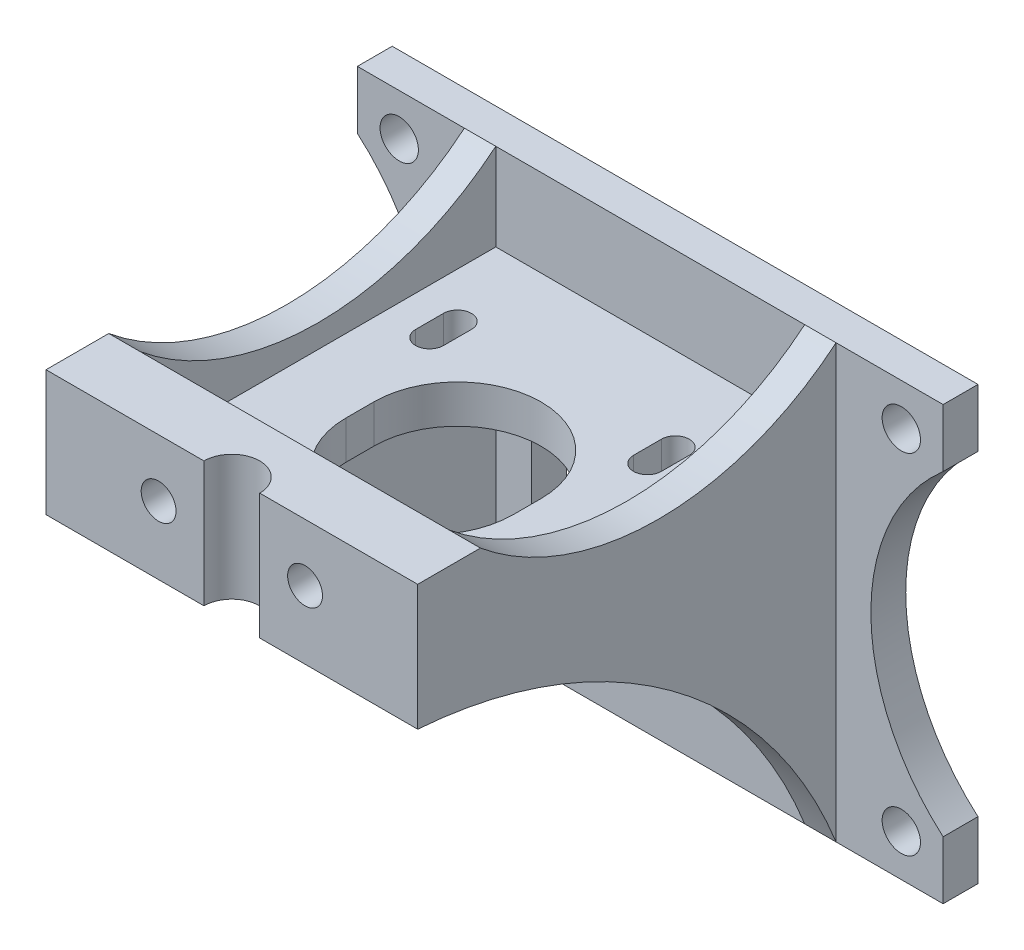
from build123d import *

# Parameters (mm, degrees)
SKETCH2_R                = 2.75
SKETCH2_W                = 34
SKETCH2_H                = 34
BOSS_EXTRUDE1_DEPTH      = 5
SKETCH3_W                = 4.5
SKETCH3_H                = 44
SKETCH3_H_2              = 18
SKETCH3_W_2              = 44.3
BOSS_EXTRUDE2_DEPTH      = 60
CUT_EXTRUDE1_DEPTH       = 16.35
CUT_EXTRUDE1_DEPTH_BACK  = 60
CUT_EXTRUDE3_DEPTH       = 16.35
CUT_EXTRUDE3_DEPTH_BACK  = 60
CUT_EXTRUDE6_REACH       = 25.5
CUT_EXTRUDE6_START       = -5.5
SKETCH9_W                = 44.3
SKETCH9_H                = 51
CUT_EXTRUDE7_DEPTH       = 5.5
LPATTERN1_COUNT          = 2
LPATTERN1_PITCH          = 31.25
LPATTERN2_COUNT          = 2
LPATTERN2_PITCH          = 31
LPATTERN2_COPY_1_DEPTH   = 5.5
CUT_EXTRUDE8_DEPTH       = 10
CUT_EXTRUDE10_DEPTH      = 45
CUT_EXTRUDE10_DEPTH_BACK = 19
SKETCH15_R               = 2.5
CUT_EXTRUDE11_DEPTH      = 4.6
LPATTERN3_COUNT          = 2
LPATTERN3_PITCH          = 21


with BuildPart() as part:
    # Sketch2 → Boss-Extrude1 (new body)
    with BuildSketch(Plane.XY):
        with BuildLine():
            Line((0, -53.68), (0, -62))
            Line((0, -62), (84, -62))
            Line((84, -62), (84, -53.68))
            ThreePointArc((84, -53.68), (73.637148469, -31), (84, -8.32))
            Line((84, -8.32), (84, 0))
            Line((84, 0), (0, 0))
            Line((0, 0), (0, -8.32))
            ThreePointArc((0, -8.32), (10.362851531, -31), (0, -53.68))
        make_face()
        with Locations((6, -6)):
            Circle(SKETCH2_R, mode=Mode.SUBTRACT)
        with Locations((78, -56)):
            Circle(SKETCH2_R, mode=Mode.SUBTRACT)
        with Locations((6, -56)):
            Circle(SKETCH2_R, mode=Mode.SUBTRACT)
        with Locations((78, -6)):
            Circle(SKETCH2_R, mode=Mode.SUBTRACT)
        with Locations((42, -37)):
            Rectangle(SKETCH2_W, SKETCH2_H, mode=Mode.SUBTRACT)
    extrude(amount=BOSS_EXTRUDE1_DEPTH)

    # Sketch3 → Boss-Extrude2 (add)
    with BuildSketch(Plane.XY.offset(5)):
        with Locations((17.6, -40)):
            Rectangle(SKETCH3_W, SKETCH3_H)
        with Locations((66.4, -40)):
            Rectangle(SKETCH3_W, SKETCH3_H)
        with Locations((66.4, -9)):
            Rectangle(SKETCH3_W, SKETCH3_H_2)
        with Locations((17.6, -9)):
            Rectangle(SKETCH3_W, SKETCH3_H_2)
        with Locations((42, -9)):
            Rectangle(SKETCH3_W_2, SKETCH3_H_2)
    extrude(amount=BOSS_EXTRUDE2_DEPTH)

    # Sketch6 → Cut-Extrude1 (cut, two sides)
    with BuildSketch(Plane(origin=(68.65, 0, 0), x_dir=(0, 0, -1), z_dir=(1, 0, 0))) as cut_extrude1_sk:
        with BuildLine():
            Line((62.328372383, -231.688052054), (-5, -62))
            ThreePointArc((-5, -62), (-28.669965475, -31.368134738), (-65, -18))
            Line((-65, -18), (-247.078635565, -4.789579558))
            Line((-247.078635565, -4.789579558), (-462.994068413, -299.219715259))
            Line((-462.994068413, -299.219715259), (-153.587060464, -526.118187755))
            Line((-153.587060464, -526.118187755), (62.328372383, -231.688052054))
        make_face()
    extrude(amount=CUT_EXTRUDE1_DEPTH, mode=Mode.SUBTRACT)
    extrude(cut_extrude1_sk.sketch, amount=-CUT_EXTRUDE1_DEPTH_BACK, mode=Mode.SUBTRACT)

    # Sketch7 → Cut-Extrude3 (cut, two sides)
    with BuildSketch(Plane(origin=(68.65, 0, 0), x_dir=(0, 0, -1), z_dir=(1, 0, 0))) as cut_extrude3_sk:
        with BuildLine():
            ThreePointArc((-56, 0), (-30.5, -9.181985788), (-5, 0))
            Line((-5, 0), (-56, 0))
        make_face()
    extrude(amount=CUT_EXTRUDE3_DEPTH, mode=Mode.SUBTRACT)
    extrude(cut_extrude3_sk.sketch, amount=-CUT_EXTRUDE3_DEPTH_BACK, mode=Mode.SUBTRACT)

    # Sketch9 → Cut-Extrude6 (cut, up to next)
    with BuildSketch(Plane.XZ.offset(18).offset(CUT_EXTRUDE6_START), mode=Mode.PRIVATE) as cut_extrude6_sk1:
        with Locations((42, 30.5)):
            Rectangle(SKETCH9_W, SKETCH9_H)
    cut_extrude6_tool1 = extrude(cut_extrude6_sk1.sketch, amount=-CUT_EXTRUDE6_REACH, mode=Mode.PRIVATE) & part.part
    add(cut_extrude6_tool1.solids().sort_by_distance((42, -12.5, 30.5))[0], mode=Mode.SUBTRACT)

    # Sketch10 → Cut-Extrude7 (cut)
    with BuildSketch(Plane(origin=(0, -12.5, 0), x_dir=(1, 0, 0), z_dir=(0, 1, 0))):
        with BuildLine():
            Line((28.35, -17), (28.35, -21))
            ThreePointArc((28.35, -21), (26.35, -23), (24.35, -21))
            Line((24.35, -21), (24.35, -17))
            ThreePointArc((24.35, -17), (26.35, -15), (28.35, -17))
        make_face()
    cut_extrude7 = extrude(amount=-CUT_EXTRUDE7_DEPTH, mode=Mode.SUBTRACT)

    # LPattern1: Cut-Extrude7 ×2
    with Locations(*[(i * LPATTERN1_PITCH, 0, 0) for i in range(1, LPATTERN1_COUNT)]):
        add(cut_extrude7, mode=Mode.SUBTRACT)

    # LPattern2: Cut-Extrude7 ×2
    with Locations(*[(0, 0, i * LPATTERN2_PITCH) for i in range(1, LPATTERN2_COUNT)]):
        add(cut_extrude7, mode=Mode.SUBTRACT)

    # LPattern2 copy 1 sketch → LPattern2 copy 1 (cut)
    with BuildSketch(Plane(origin=(31.25, -12.5, 31), x_dir=(1, 0, 0), z_dir=(0, 1, 0))):
        with BuildLine():
            Line((28.35, -17), (28.35, -21))
            ThreePointArc((28.35, -21), (26.35, -23), (24.35, -21))
            Line((24.35, -21), (24.35, -17))
            ThreePointArc((24.35, -17), (26.35, -15), (28.35, -17))
        make_face()
    extrude(amount=-LPATTERN2_COPY_1_DEPTH, mode=Mode.SUBTRACT)

    # Sketch11 → Cut-Extrude8 (cut)
    with BuildSketch(Plane(origin=(0, -12.5, 0), x_dir=(1, 0, 0), z_dir=(0, 1, 0))):
        with BuildLine():
            Line((54.35, -33), (54.35, -37))
            ThreePointArc((54.35, -37), (42.35, -49), (30.35, -37))
            Line((30.35, -37), (30.35, -33))
            ThreePointArc((30.35, -33), (42.35, -21), (54.35, -33))
        make_face()
    extrude(amount=-CUT_EXTRUDE8_DEPTH, mode=Mode.SUBTRACT)

    # Sketch14 → Cut-Extrude10 (cut, two sides)
    with BuildSketch(Plane.XZ.offset(18)) as cut_extrude10_sk:
        with BuildLine():
            Line((38, 234.260792413), (38, 65))
            ThreePointArc((38, 65), (42, 61), (46, 65))
            Line((46, 65), (46, 234.260792413))
            Line((46, 234.260792413), (46, 572.782377239))
            Line((46, 572.782377239), (38, 572.782377239))
            Line((38, 572.782377239), (38, 234.260792413))
        make_face()
    extrude(amount=CUT_EXTRUDE10_DEPTH, mode=Mode.SUBTRACT)
    extrude(cut_extrude10_sk.sketch, amount=-CUT_EXTRUDE10_DEPTH_BACK, mode=Mode.SUBTRACT)

    # Sketch15 → Cut-Extrude11 (cut)
    with BuildSketch(Plane.XY.offset(65)):
        with Locations((31.5, -8.25)):
            Circle(SKETCH15_R)
    cut_extrude11 = extrude(amount=-CUT_EXTRUDE11_DEPTH, mode=Mode.SUBTRACT)

    # LPattern3: Cut-Extrude11 ×2
    with Locations(*[(i * LPATTERN3_PITCH, 0, 0) for i in range(1, LPATTERN3_COUNT)]):
        add(cut_extrude11, mode=Mode.SUBTRACT)


solid = part.part
